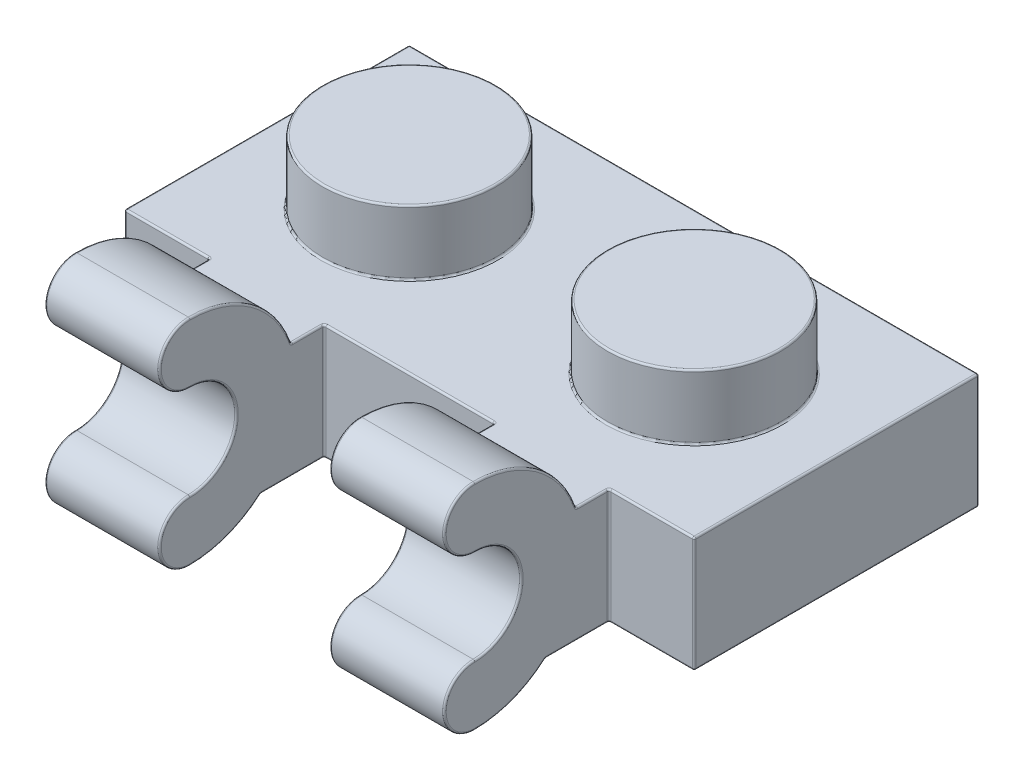
from build123d import *

# Parameters (mm, degrees)
SKETCH1_W       = 7.96
SKETCH1_H       = 7.96
EXTRUDE1_DEPTH  = 3.22
SKETCH2_R       = 2.425
EXTRUDE2_DEPTH  = 1.8
LPATTERN1_COUNT = 2
LPATTERN1_PITCH = 7.96
SHELL1_T        = -1.55
SKETCH4_W       = 12.82
SKETCH4_H       = 4.86
EXTRUDE3_DEPTH  = 0.14
SKETCH5_R       = 1.5
SKETCH5_R_2     = 0.64
EXTRUDE4_DEPTH  = 1.81
EXTRUDE6_DEPTH  = 1.6
LPATTERN2_COUNT = 2
LPATTERN2_PITCH = 7.96
FILLET1_R       = 0.05


with BuildPart() as part:
    # Sketch1 → Extrude1 (new body)
    with BuildSketch(Plane(origin=(0, 0, 0), x_dir=(1, 0, 0), z_dir=(0, 1, 0))):
        Rectangle(SKETCH1_W, SKETCH1_H)
    extrude1 = extrude(amount=EXTRUDE1_DEPTH)

    # Sketch2 → Extrude2 (add)
    with BuildSketch(Plane(origin=(0, 3.22, 0), x_dir=(1, 0, 0), z_dir=(0, 1, 0))):
        Circle(SKETCH2_R)
    extrude2 = extrude(amount=EXTRUDE2_DEPTH)

    # LPattern1: Extrude1, Extrude2 ×2
    with Locations(*[(i * LPATTERN1_PITCH, 0, 0) for i in range(1, LPATTERN1_COUNT)]):
        add(extrude1)
        add(extrude2)

    # Shell1
    shell1_openings = [part.faces().sort_by_distance(p)[0] for p in [
        (3.98, 0, 0),
    ]]
    offset(amount=SHELL1_T, openings=shell1_openings, kind=Kind.INTERSECTION)

    # Sketch4 → Extrude3 (cut)
    with BuildSketch(Plane.XZ.offset(-1.67)):
        with Locations((3.98, 0)):
            Rectangle(SKETCH4_W, SKETCH4_H)
    extrude(amount=-EXTRUDE3_DEPTH, mode=Mode.SUBTRACT)

    # Sketch5 → Extrude4 (add)
    with BuildSketch(Plane.XZ.offset(-1.81)):
        with Locations((3.98, 0)):
            Circle(SKETCH5_R)
        with Locations((3.98, 0)):
            Circle(SKETCH5_R_2, mode=Mode.SUBTRACT)
    extrude(amount=EXTRUDE4_DEPTH)

    # Sketch7 → Extrude6 (add, symmetric)
    with BuildSketch(Plane(origin=(0, 0, 0), x_dir=(0, 0, -1), z_dir=(1, 0, 0))):
        with BuildLine():
            Line((-3.98, 3.22), (-3.98, 0))
            Line((-3.98, 0), (-5.745686517, 0))
            ThreePointArc((-5.745686517, 0), (-6.669339828, -0.55624304), (-7.73, -0.75))
            ThreePointArc((-7.73, -0.75), (-8.58, 0.1), (-7.73, 0.95))
            ThreePointArc((-7.73, 0.95), (-6.43, 2.25), (-7.73, 3.55))
            ThreePointArc((-7.73, 3.55), (-8.58, 4.4), (-7.73, 5.25))
            ThreePointArc((-7.73, 5.25), (-5.985007163, 4.690286868), (-4.891144597, 3.22))
            Line((-4.891144597, 3.22), (-3.98, 3.22))
        make_face()
    extrude6 = extrude(amount=EXTRUDE6_DEPTH, both=True)

    # LPattern2: Extrude6 ×2
    with Locations(*[(i * LPATTERN2_PITCH, 0, 0) for i in range(1, LPATTERN2_COUNT)]):
        add(extrude6)

    # Fillet1
    fillet1_edges = [part.edges().sort_by_distance(p)[0] for p in [
        (-3.98, 3.22, 0),
        (9.56, 4.690286868, 5.985007163),
        (9.56, 4.4, 8.58),
        (9.56, 2.25, 6.43),
        (9.56, 0.1, 8.58),
        (9.56, -0.55624304, 6.669339828),
        (9.56, 0, 4.862843258),
        (9.56, 1.61, 3.98),
        (-2.79, 3.22, 3.98),
        (-2.425, 3.22, 0),
        (-2.425, 5.02, 0),
        (11.94, 0, 0),
        (11.94, 1.61, 3.98),
        (11.94, 1.61, -3.98),
        (11.94, 3.22, 0),
        (5.535, 3.22, 0),
        (5.535, 5.02, 0),
        (3.98, 0, -2.43),
        (10.39, 0.905, -2.43),
        (-2.43, 0, 0),
        (-2.43, 0.905, -2.43),
        (3.98, 0, 2.43),
        (-2.43, 0.905, 2.43),
        (-0.875, 3.47, 0),
        (10.39, 0, 0),
        (10.39, 0.905, 2.43),
        (7.085, 3.47, 0),
        (-2.79, 0, 3.98),
        (-0.875, 1.81, 0),
        (7.085, 1.81, 0),
        (3.98, 1.81, 2.43),
        (10.39, 1.81, 0),
        (-3.98, 0, 0),
        (3.98, 1.81, -2.43),
        (-2.43, 1.81, 0),
        (3.98, 0, -3.98),
        (2.48, 1.81, 0),
        (3.34, 1.81, 0),
        (2.48, 0, 0),
        (3.34, 0, 0),
        (3.98, 3.22, -3.98),
        (3.98, 0, 3.98),
        (3.98, 3.22, 3.98),
        (0, 3.22, 4.891144597),
        (-1.6, 3.22, 4.435572298),
        (-1.6, 1.61, 3.98),
        (-1.6, 0, 4.862843258),
        (0, 0, 5.745686517),
        (-1.6, -0.55624304, 6.669339828),
        (-3.98, 1.61, 3.98),
        (-1.6, 0.1, 8.58),
        (-1.6, 2.25, 6.43),
        (-1.6, 4.4, 8.58),
        (-3.98, 1.61, -3.98),
        (-1.6, 4.690286868, 5.985007163),
        (1.6, 3.22, 4.435572298),
        (1.6, 4.690286868, 5.985007163),
        (1.6, 4.4, 8.58),
        (1.6, 2.25, 6.43),
        (1.6, 0.1, 8.58),
        (1.6, -0.55624304, 6.669339828),
        (1.6, 0, 4.862843258),
        (1.6, 1.61, 3.98),
        (10.75, 0, 3.98),
        (10.75, 3.22, 3.98),
        (7.96, 3.22, 4.891144597),
        (6.36, 3.22, 4.435572298),
        (6.36, 1.61, 3.98),
        (6.36, 0, 4.862843258),
        (7.96, 0, 5.745686517),
        (6.36, -0.55624304, 6.669339828),
        (6.36, 0.1, 8.58),
        (6.36, 2.25, 6.43),
        (6.36, 4.4, 8.58),
        (6.36, 4.690286868, 5.985007163),
        (9.56, 3.22, 4.435572298),
    ]]
    fillet(fillet1_edges, radius=FILLET1_R)


solid = part.part
